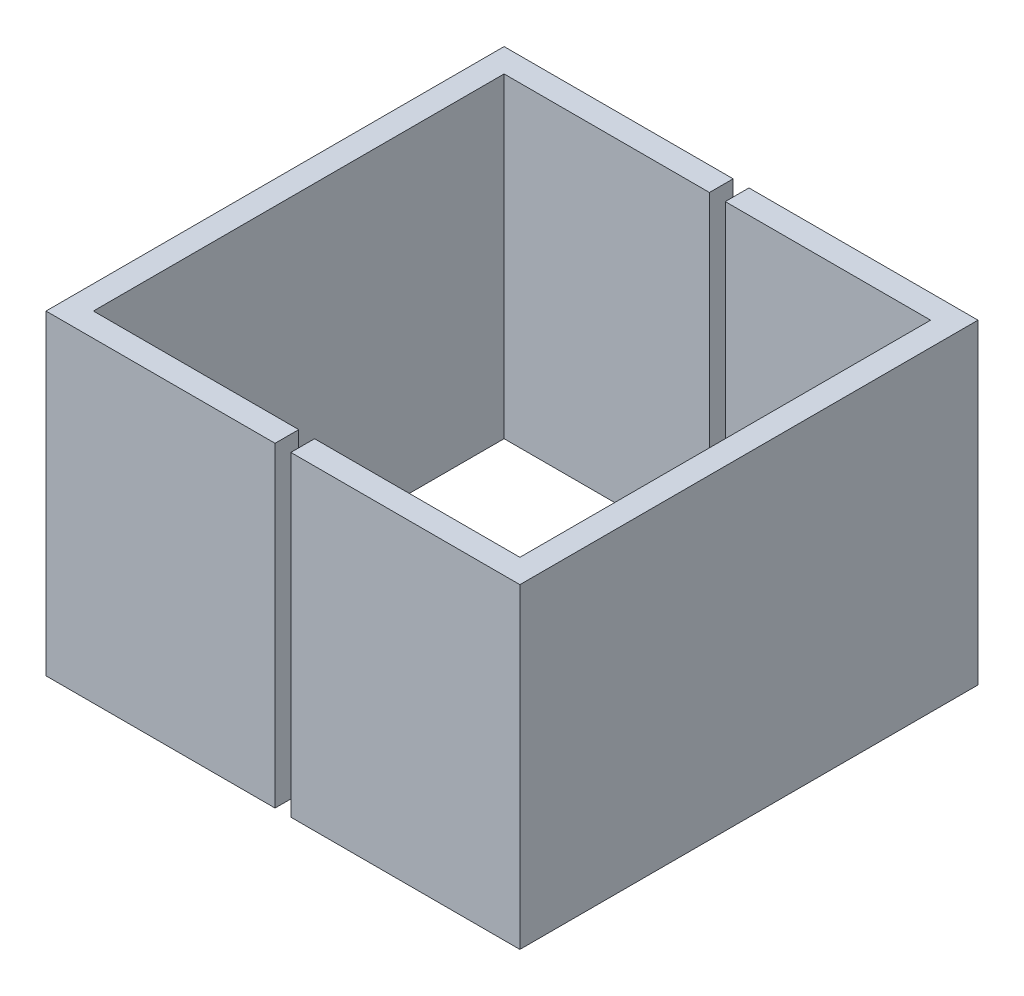
from build123d import *

# Parameters (mm, degrees)
SKETCH1_W           = 30
SKETCH1_H           = 29
SKETCH1_W_2         = 27
SKETCH1_H_2         = 26
BOSS_EXTRUDE1_DEPTH = 20
SKETCH2_W           = 1
SKETCH2_H           = 29
CUT_EXTRUDE1_DEPTH  = 21


with BuildPart() as part:
    # Sketch1 → Boss-Extrude1 (new body)
    with BuildSketch(Plane(origin=(0, 0, 0), x_dir=(1, 0, 0), z_dir=(0, 1, 0))):
        Rectangle(SKETCH1_W, SKETCH1_H)
        Rectangle(SKETCH1_W_2, SKETCH1_H_2, mode=Mode.SUBTRACT)
    extrude(amount=BOSS_EXTRUDE1_DEPTH)

    # Sketch2 → Cut-Extrude1 (cut, through all)
    with BuildSketch(Plane(origin=(0, 20, 0), x_dir=(1, 0, 0), z_dir=(0, 1, 0))):
        Rectangle(SKETCH2_W, SKETCH2_H)
    extrude(amount=-CUT_EXTRUDE1_DEPTH, mode=Mode.SUBTRACT)


solid = part.part
